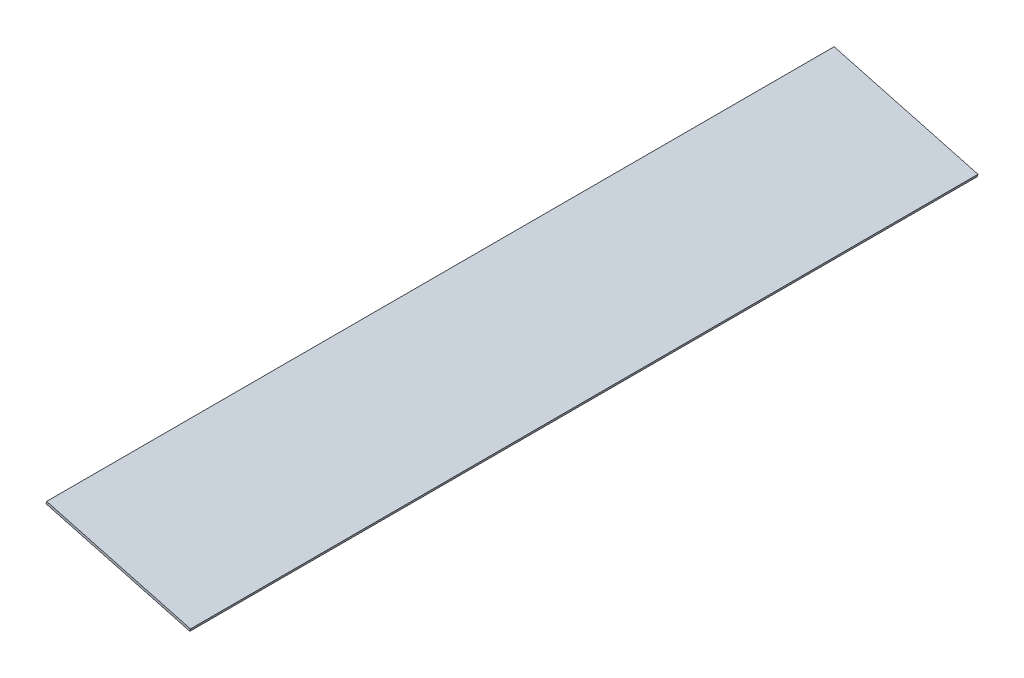
from build123d import *

# Parameters (mm, degrees)
BOSS_EXTRUDE1_DEPTH = 511.175


with BuildPart() as part:
    # Sketch1 → Boss-Extrude1 (new body)
    with BuildSketch(Plane.XY):
        Polygon((0, 0), (-93.372179155, 25.019), (-92.96130392, 26.552407249), (0.410875234, 1.533407249), align=None)
    extrude(amount=BOSS_EXTRUDE1_DEPTH)


solid = part.part
